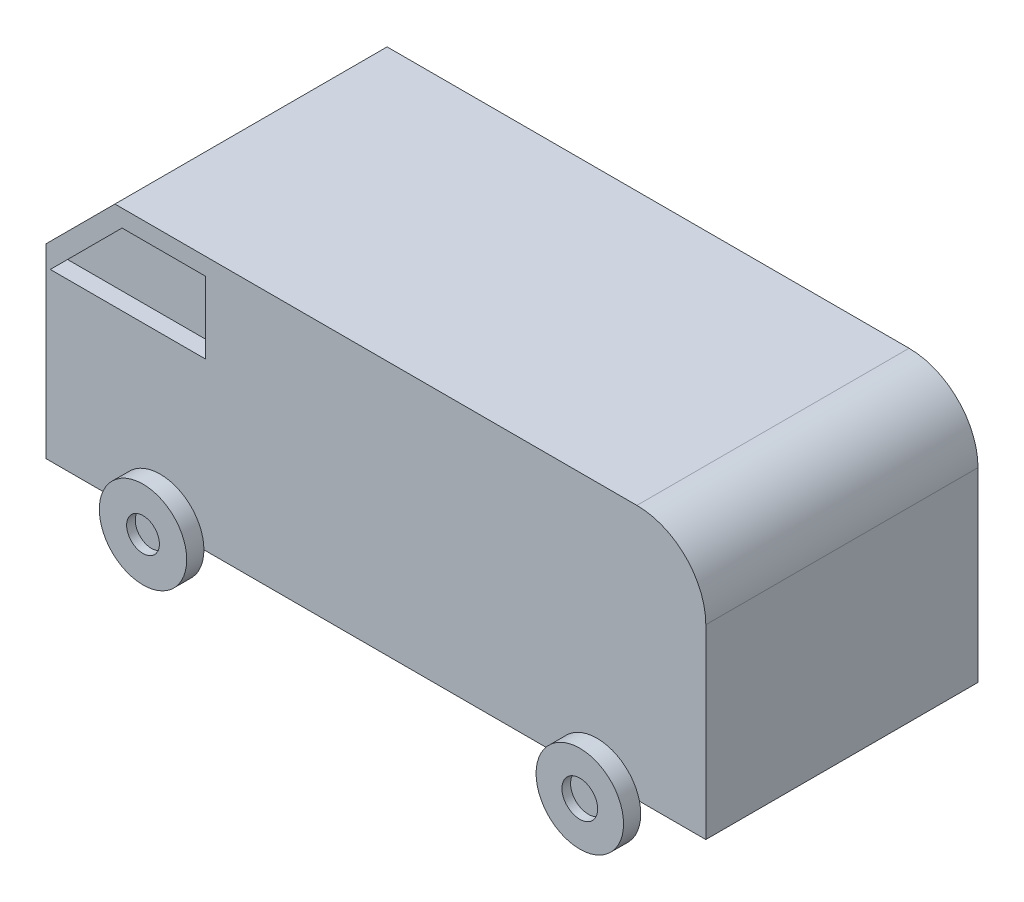
from build123d import *

# Parameters (mm, degrees)
SKETCH1_W           = 383
SKETCH1_H           = 158
BOSS_EXTRUDE1_DEPTH = 148
CHAMFER1_SIZE       = 40
FILLET2_R           = 40
CUT_EXTRUDE1_DEPTH  = 10
SKETCH3_R           = 25.359004934
SKETCH3_R_2         = 25.38354828
SKETCH3_R_3         = 0.078937569
BOSS_EXTRUDE2_DEPTH = 10
SKETCH4_R           = 25.379630878
SKETCH4_R_2         = 25.14023966
BOSS_EXTRUDE3_DEPTH = 10
SKETCH5_R           = 14.322762403
SKETCH5_R_2         = 16.232376453
BOSS_EXTRUDE4_DEPTH = 10
SKETCH6_R           = 9.520267446
SKETCH6_R_2         = 10.36710352
CUT_EXTRUDE3_DEPTH  = 5


with BuildPart() as part:
    # Sketch1 → Boss-Extrude1 (new body)
    with BuildSketch(Plane(origin=(0, 0, 0), x_dir=(1, 0, 0), z_dir=(0, 1, 0))):
        Rectangle(SKETCH1_W, SKETCH1_H)
    extrude(amount=BOSS_EXTRUDE1_DEPTH)

    # Chamfer1
    chamfer1_edges = [part.edges().sort_by_distance(p)[0] for p in [
        (-191.5, 148, 0),
    ]]
    chamfer(chamfer1_edges, length=CHAMFER1_SIZE)

    # Fillet2
    fillet2_edges = [part.edges().sort_by_distance(p)[0] for p in [
        (191.5, 148, 0),
    ]]
    fillet(fillet2_edges, radius=FILLET2_R)

    # Sketch2 → Cut-Extrude1 (cut)
    with BuildSketch(Plane.XY.offset(79)):
        Polygon((-98.997864376, 96.36), (-98.997864376, 138), (-147.357864376, 138), (-188.997864376, 96.36), align=None)
    extrude(amount=-CUT_EXTRUDE1_DEPTH, mode=Mode.SUBTRACT)

    # Sketch3 → Boss-Extrude2 (add)
    with BuildSketch(Plane.XY.offset(79)):
        with Locations((-125.190072904, 0)):
            Circle(SKETCH3_R)
        with Locations(Location((128.359085281, -6.01772291, 0), (0, 0, 166.286221503))):  # turned: the seam where the file's is
            Circle(SKETCH3_R_2)
        with Locations((121.138153371, 0)):
            Circle(SKETCH3_R_3, mode=Mode.SUBTRACT)
    extrude(amount=BOSS_EXTRUDE2_DEPTH)

    # Sketch4 → Boss-Extrude3 (add)
    with BuildSketch(Plane(origin=(0, 0, -79), x_dir=(-1, 0, 0), z_dir=(0, 0, -1))):
        with Locations((-132.542849772, 0)):
            Circle(SKETCH4_R)
        with Locations((116.282098448, 0)):
            Circle(SKETCH4_R_2)
    extrude(amount=BOSS_EXTRUDE3_DEPTH)

    # Sketch5 → Boss-Extrude4 (add)
    with BuildSketch(Plane.ZY.offset(191.5)):
        with Locations(Location((-53.71948852, 34.670472679, 0), (0, 0, 180))):  # turned: the seam where the file's is
            Circle(SKETCH5_R)
        with Locations(Location((30.280445708, 34.670472679, 0), (0, 0, 180))):  # turned: the seam where the file's is
            Circle(SKETCH5_R_2)
    extrude(amount=BOSS_EXTRUDE4_DEPTH)

    # Sketch6 → Cut-Extrude3 (cut)
    with BuildSketch(Plane.XY.offset(89)):
        with Locations((-125.190072904, 0)):
            Circle(SKETCH6_R)
        with Locations((128.359085281, -6.01772291)):
            Circle(SKETCH6_R_2)
    extrude(amount=-CUT_EXTRUDE3_DEPTH, mode=Mode.SUBTRACT)


solid = part.part
